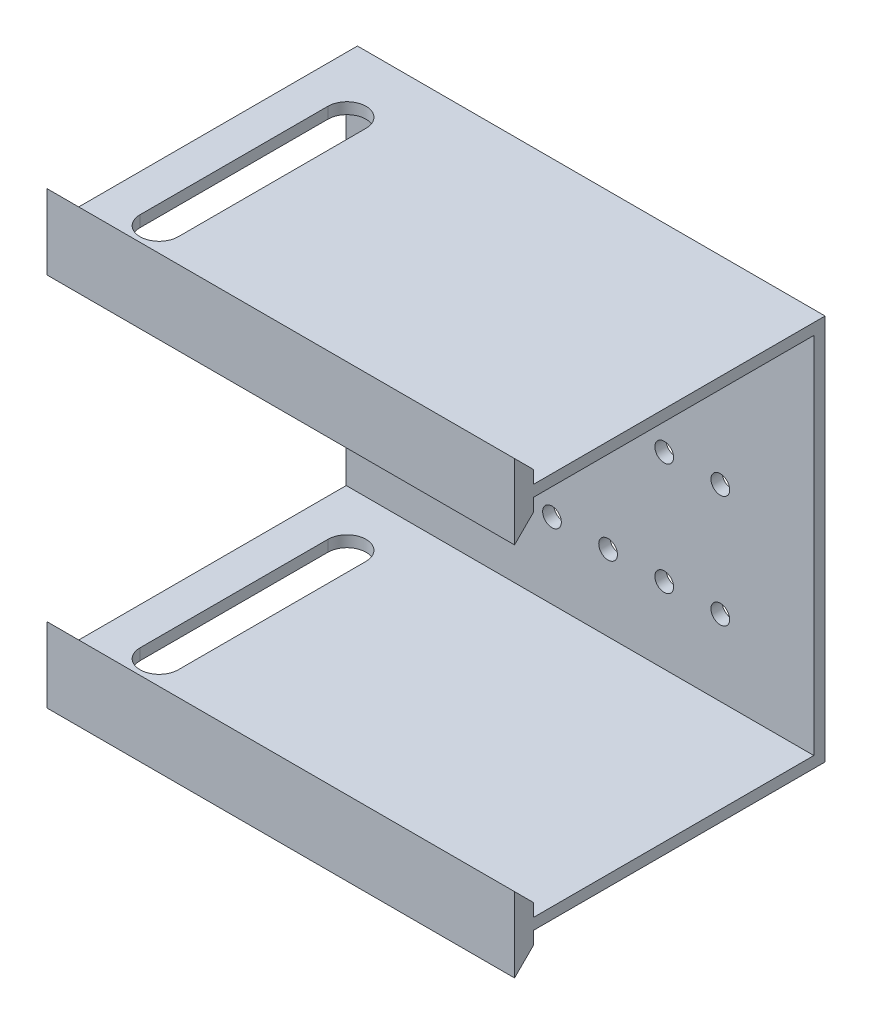
from build123d import *

# Parameters (mm, degrees)
ESQUISSE1_W             = 125
ESQUISSE1_H             = 80
BOSS_EXTRU_1_DEPTH      = 3
ESQUISSE2_W             = 125
ESQUISSE2_H             = 103.25
BOSS_EXTRU_2_DEPTH      = 3
ESQUISSE6_W             = 5
ESQUISSE6_H             = 3.5
BOSS_EXTRU_5_DEPTH      = 125
ESQUISSE7_R             = 2.5
ENL_V_MAT_EXTRU_2_DEPTH = 3


with BuildPart() as part:
    # Esquisse1 → Boss.-Extru.1 (new body)
    with BuildSketch(Plane(origin=(0, 0, 0), x_dir=(1, 0, 0), z_dir=(0, 1, 0))):
        with Locations((52.5, 25.1)):
            Rectangle(ESQUISSE1_W, ESQUISSE1_H)
        with BuildLine():
            ThreePointArc((10.2, 0), (5.1, -5.1), (0, 0))
            Line((0, 0), (0, 50.2))
            ThreePointArc((0, 50.2), (5.1, 55.3), (10.2, 50.2))
            Line((10.2, 50.2), (10.2, 0))
        make_face(mode=Mode.SUBTRACT)
    boss_extru_1 = extrude(amount=BOSS_EXTRU_1_DEPTH)

    # Esquisse2 → Boss.-Extru.2 (add)
    with BuildSketch(Plane(origin=(0, 0, -65.1), x_dir=(-1, 0, 0), z_dir=(0, 0, -1))):
        with Locations((-52.5, -48.625)):
            Rectangle(ESQUISSE2_W, ESQUISSE2_H)
    extrude(amount=BOSS_EXTRU_2_DEPTH)

    # Symétrie1: Boss.-Extru.1 across plane
    add(boss_extru_1.mirror(Plane(origin=(0, -48.625, 0), x_dir=(0, 0, 1), z_dir=(0, -1, 0))))

    # Esquisse6 → Boss.-Extru.5 (add)
    with BuildSketch(Plane(origin=(115, 0, 0), x_dir=(0, 0, -1), z_dir=(1, 0, 0))):
        with Locations((-12.4, -95.5)):
            Rectangle(ESQUISSE6_W, ESQUISSE6_H)
        with Locations((-12.4, -102)):
            Rectangle(ESQUISSE6_W, ESQUISSE6_H)
        Polygon((-14.9, -103.75), (-9.9, -103.75), (-14.9, -108.75), align=None)
        Polygon((-14.9, -93.75), (-14.9, -88.75), (-9.9, -93.75), align=None)
        Polygon((-14.9, -3.5), (-14.9, -8.5), (-9.9, -3.5), align=None)
        with Locations((-12.4, -1.75)):
            Rectangle(ESQUISSE6_W, ESQUISSE6_H)
        with Locations((-12.4, 4.75)):
            Rectangle(ESQUISSE6_W, ESQUISSE6_H)
        Polygon((-14.9, 11.5), (-9.9, 6.5), (-14.9, 6.5), align=None)
    extrude(amount=-BOSS_EXTRU_5_DEPTH)

    # Esquisse7 → Enlèv. mat.-Extru.2 (cut)
    with BuildSketch(Plane(origin=(0, 0, -68.1), x_dir=(-1, 0, 0), z_dir=(0, 0, -1))):
        with Locations((-90, -17)):
            Circle(ESQUISSE7_R)
        with Locations((-75, -17)):
            Circle(ESQUISSE7_R)
        with Locations((-60, -17)):
            Circle(ESQUISSE7_R)
        with Locations((-45, -17)):
            Circle(ESQUISSE7_R)
        with Locations((-30, -17)):
            Circle(ESQUISSE7_R)
        with Locations((-15, -17)):
            Circle(ESQUISSE7_R)
        with Locations((-75, -47)):
            Circle(ESQUISSE7_R)
        with Locations((-60, -47)):
            Circle(ESQUISSE7_R)
        with Locations((-45, -47)):
            Circle(ESQUISSE7_R)
        with Locations((-30, -47)):
            Circle(ESQUISSE7_R)
        with Locations((-15, -47)):
            Circle(ESQUISSE7_R)
        with Locations((-75, -77)):
            Circle(ESQUISSE7_R)
        with Locations((-60, -77)):
            Circle(ESQUISSE7_R)
        with Locations((-45, -77)):
            Circle(ESQUISSE7_R)
        with Locations((-30, -77)):
            Circle(ESQUISSE7_R)
        with Locations((-15, -77)):
            Circle(ESQUISSE7_R)
        with Locations((-90, -47)):
            Circle(ESQUISSE7_R)
        with Locations((-90, -77)):
            Circle(ESQUISSE7_R)
    extrude(amount=-ENL_V_MAT_EXTRU_2_DEPTH, mode=Mode.SUBTRACT)


solid = part.part
